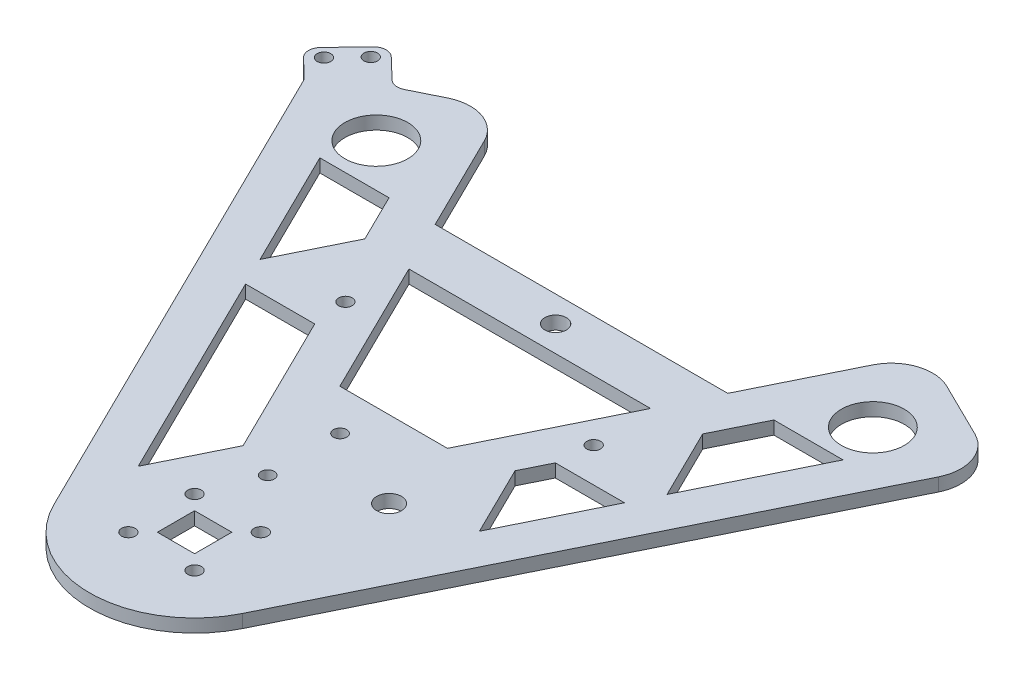
from build123d import *

# Parameters (mm, degrees)
SKETCH1_R               = 1.65
SKETCH1_W               = 9
SKETCH1_H               = 9
SKETCH1_R_2             = 1.6
SKETCH1_R_3             = 3
SKETCH1_R_4             = 7.6
SKETCH1_R_5             = 2.6
BOSS_EXTRUDE1_DEPTH     = 3.175
FILLET1_R               = 10
CUT_EXTRUDE1_DEPTH      = 1
CUT_EXTRUDE1_DEPTH_BACK = 4.175
SKETCH3_R               = 1.65
BOSS_EXTRUDE2_DEPTH     = 3.175
FILLET2_R               = 3


with BuildPart() as part:
    # Sketch1 → Boss-Extrude1 (new body)
    with BuildSketch(Plane(origin=(0, 0, 0), x_dir=(1, 0, 0), z_dir=(0, 1, 0))):
        with BuildLine():
            Line((-51.31658538, 125.897213638), (-82.713802404, 110.430644428))
            Line((-82.713802404, 110.430644428), (-22.785408926, -11.224310227))
            ThreePointArc((-22.785408926, -11.224310227), (0, -25.4), (22.785408926, -11.224310227))
            Line((22.785408926, -11.224310227), (82.713802404, 110.430644428))
            Line((82.713802404, 110.430644428), (51.31658538, 125.897213638))
            Line((51.31658538, 125.897213638), (35.357408279, 93.5))
            Line((35.357408279, 93.5), (-35.357408279, 93.5))
            Line((-35.357408279, 93.5), (-51.31658538, 125.897213638))
        make_face()
        Polygon((-29.1997888, 81), (29.1997888, 81), (13, 48.114343343), (-13, 48.114343343), align=None, mode=Mode.SUBTRACT)
        with Locations((-8, -8)):
            Circle(SKETCH1_R, mode=Mode.SUBTRACT)
        Rectangle(SKETCH1_W, SKETCH1_H, mode=Mode.SUBTRACT)
        with Locations((-8, 8)):
            Circle(SKETCH1_R, mode=Mode.SUBTRACT)
        with Locations((-3.1, 20.76053754)):
            Circle(SKETCH1_R_2, mode=Mode.SUBTRACT)
        with Locations((8, -8)):
            Circle(SKETCH1_R, mode=Mode.SUBTRACT)
        with Locations((8, 8)):
            Circle(SKETCH1_R, mode=Mode.SUBTRACT)
        with Locations((17.5, 29.51053754)):
            Circle(SKETCH1_R_3, mode=Mode.SUBTRACT)
        with Locations((-30, 66.453060464)):
            Circle(SKETCH1_R, mode=Mode.SUBTRACT)
        with Locations((-60, 103.923048454)):
            Circle(SKETCH1_R_4, mode=Mode.SUBTRACT)
        with Locations((30, 66.453060464)):
            Circle(SKETCH1_R, mode=Mode.SUBTRACT)
        with Locations((60, 103.923048454)):
            Circle(SKETCH1_R_4, mode=Mode.SUBTRACT)
        with Locations((0, 87.25)):
            Circle(SKETCH1_R_5, mode=Mode.SUBTRACT)
        with Locations((-3.1, 38.26053754)):
            Circle(SKETCH1_R_2, mode=Mode.SUBTRACT)
    extrude(amount=BOSS_EXTRUDE1_DEPTH)

    # Fillet1
    fillet1_edges = [part.edges().sort_by_distance(p)[0] for p in [
        (51.31658538, 1.5875, -125.897213638),
        (82.713802404, 1.5875, -110.430644428),
        (-82.713802404, 1.5875, -110.430644428),
        (-51.31658538, 1.5875, -125.897213638),
    ]]
    fillet(fillet1_edges, radius=FILLET1_R)

    # Sketch2 → Cut-Extrude1 (cut, two sides)
    with BuildSketch(Plane(origin=(0, 3.175, 0), x_dir=(1, 0, 0), z_dir=(0, 1, 0))) as cut_extrude1_sk:
        Polygon((-45.79480762, 58.114343343), (-29.073580398, 58.114343343), (-12.254779912, 23.972089701), (-20.615393523, 7), align=None)
        Polygon((-63.226120316, 93.5), (-49.186747904, 65), (-40.826134293, 81.972089701), (-46.504893094, 93.5), align=None)
        Polygon((29.073580398, 58.114343343), (45.79480762, 58.114343343), (34.218483, 34.614343343), (25.857869389, 51.586433044), align=None)
        Polygon((46.504893094, 93.5), (63.226120316, 93.5), (49.186747904, 65), (40.826134293, 81.972089701), align=None)
    extrude(amount=CUT_EXTRUDE1_DEPTH, mode=Mode.SUBTRACT)
    extrude(cut_extrude1_sk.sketch, amount=-CUT_EXTRUDE1_DEPTH_BACK, mode=Mode.SUBTRACT)

    # Sketch3 → Boss-Extrude2 (add)
    with BuildSketch(Plane(origin=(0, 0, 0), x_dir=(1, 0, 0), z_dir=(0, 1, 0))):
        with BuildLine():
            Line((-69.257852251, 117.059174089), (-77.922641378, 125.361067209))
            Line((-77.922641378, 125.361067209), (-88.300007778, 114.5300808))
            Line((-88.300007778, 114.5300808), (-81.545013782, 108.057997365))
            Line((-81.545013782, 108.057997365), (-78.29478263, 101.460010992))
            ThreePointArc((-78.29478263, 101.460010992), (-78.792063776, 109.097507652), (-73.743168968, 114.849664202))
            Line((-73.743168968, 114.849664202), (-69.257852251, 117.059174089))
        make_face()
        with Locations((-78.17782959, 120.758363767)):
            Circle(SKETCH3_R, mode=Mode.SUBTRACT)
        with Locations((-83.712425003, 114.981837682)):
            Circle(SKETCH3_R, mode=Mode.SUBTRACT)
    extrude(amount=BOSS_EXTRUDE2_DEPTH)

    # Fillet2
    fillet2_edges = [part.edges().sort_by_distance(p)[0] for p in [
        (-81.545013782, 1.5875, -108.057997365),
        (-88.300007778, 1.5875, -114.5300808),
        (-77.922641378, 1.5875, -125.361067209),
        (-69.257852251, 1.5875, -117.059174089),
    ]]
    fillet(fillet2_edges, radius=FILLET2_R)


solid = part.part
